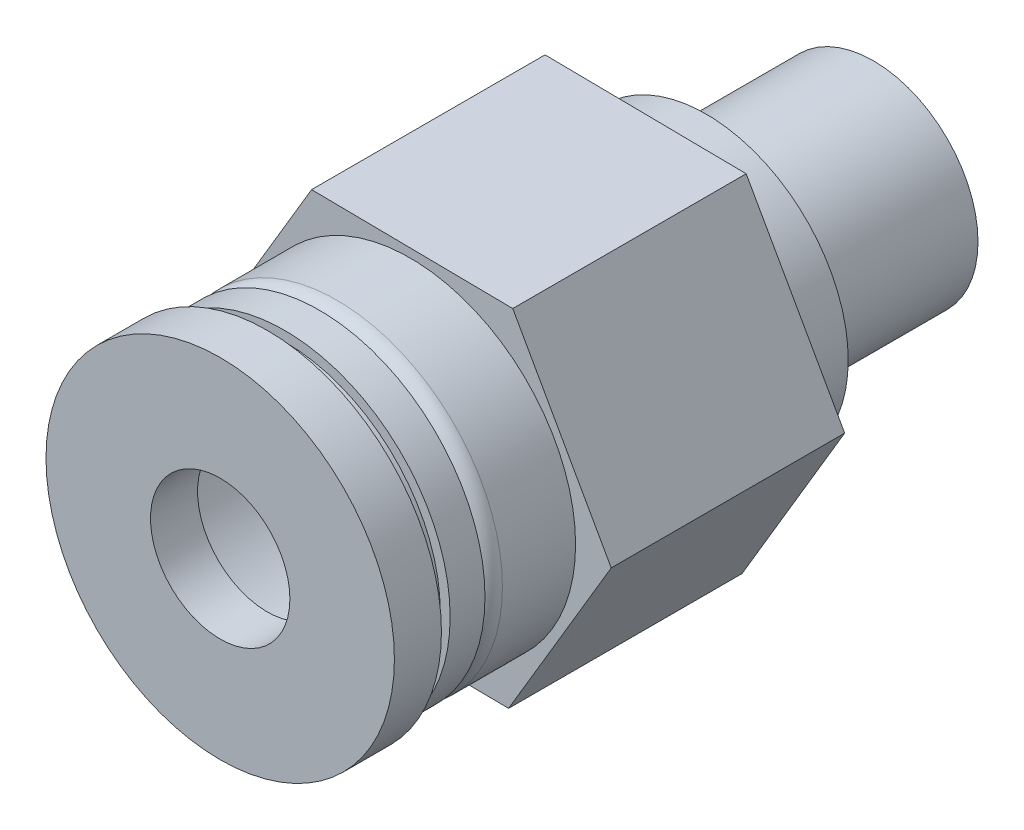
from build123d import *

# Parameters (mm, degrees)
SKETCH_1_R          = 3
EXTRUDE_1_DEPTH     = 6.7
SKETCH_2_R          = 3
EXTRUDE_2_DEPTH     = 6.7
SKETCH_3_R          = 3.2
CUT_EXTRUDE_1_DEPTH = 0.1
SKETCH_4_R          = 2.15
CUT_EXTRUDE_2_DEPTH = 12.6
SKETCH_5_R          = 4.75
SKETCH_5_R_2        = 3.75
EXTRUDE_3_DEPTH     = 2.6
FILLET_1_R          = 0.5
SKETCH_6_R          = 4.75
SKETCH_6_R_2        = 3.75
EXTRUDE_4_DEPTH     = 1
SKETCH_7_R          = 4.465730979
SKETCH_7_R_2        = 4.177014906
EXTRUDE_5_DEPTH     = 0.5
SKETCH_8_R          = 5
SKETCH_8_R_2        = 2
EXTRUDE_6_DEPTH     = 1.35
SKETCH_9_R          = 4.075
SKETCH_9_R_2        = 3
EXTRUDE_7_DEPTH     = 1.8


with BuildPart() as part:
    # 草图1 → 凸台-拉伸1 (new body)
    with BuildSketch(Plane.XY):
        Circle(SKETCH_1_R)
    extrude(amount=EXTRUDE_1_DEPTH)

    # 草图3 → 切除-拉伸1 (cut)
    with BuildSketch(Plane(origin=(0, 0, 0), x_dir=(-1, 0, 0), z_dir=(0, 0, -1))):
        Circle(SKETCH_3_R)
    extrude(amount=-CUT_EXTRUDE_1_DEPTH, mode=Mode.SUBTRACT)

    # 草图4 → 切除-拉伸2 (cut)
    with BuildSketch(Plane(origin=(0, 0, 0.1), x_dir=(-1, 0, 0), z_dir=(0, 0, -1))):
        Circle(SKETCH_4_R)
    extrude(amount=-CUT_EXTRUDE_2_DEPTH, mode=Mode.SUBTRACT)



with BuildPart() as body_2:
    # 草图2 → 凸台-拉伸2 (new body)
    with BuildSketch(Plane.XY.offset(6.7)):
        Polygon((2.82688706, -5.034088089), (5.7730917, -0.068888037), (2.946204639, 4.965200052), (-2.82688706, 5.034088089), (-5.7730917, 0.068888037), (-2.946204639, -4.965200052), align=None)
        Circle(SKETCH_2_R, mode=Mode.SUBTRACT)
    extrude(amount=EXTRUDE_2_DEPTH)

    # 草图5 → 凸台-拉伸3 (add)
    with BuildSketch(Plane.XY.offset(13.4)):
        Circle(SKETCH_5_R)
        Circle(SKETCH_5_R_2, mode=Mode.SUBTRACT)
    extrude(amount=EXTRUDE_3_DEPTH)

    # 圆角1
    fillet_1_edges = [body_2.edges().sort_by_distance(p)[0] for p in [
        (-4.75, 0, 16),
    ]]
    fillet(fillet_1_edges, radius=FILLET_1_R)

    # 草图6 → 凸台-拉伸4 (add)
    with BuildSketch(Plane.XY.offset(16)):
        Circle(SKETCH_6_R)
        Circle(SKETCH_6_R_2, mode=Mode.SUBTRACT)
    extrude(amount=EXTRUDE_4_DEPTH)


with BuildPart() as body_3:
    # 草图7 → 凸台-拉伸5 (new body)
    with BuildSketch(Plane.XY.offset(17)):
        Circle(SKETCH_7_R)
        Circle(SKETCH_7_R_2, mode=Mode.SUBTRACT)
    extrude(amount=EXTRUDE_5_DEPTH)

    # 草图8 → 凸台-拉伸6 (add)
    with BuildSketch(Plane.XY.offset(17.5)):
        Circle(SKETCH_8_R)
        Circle(SKETCH_8_R_2, mode=Mode.SUBTRACT)
    extrude(amount=EXTRUDE_6_DEPTH)


with BuildPart() as part_1:
    add(part.part)

    add(body_2.part)  # 凸台-拉伸7 merges body 2
    # 草图9 → 凸台-拉伸7 (add)
    with BuildSketch(Plane(origin=(0, 0, 6.7), x_dir=(-1, 0, 0), z_dir=(0, 0, -1))):
        Circle(SKETCH_9_R)
        Circle(SKETCH_9_R_2, mode=Mode.SUBTRACT)
    extrude(amount=EXTRUDE_7_DEPTH)


solid = Compound([body_3.part, part_1.part])
